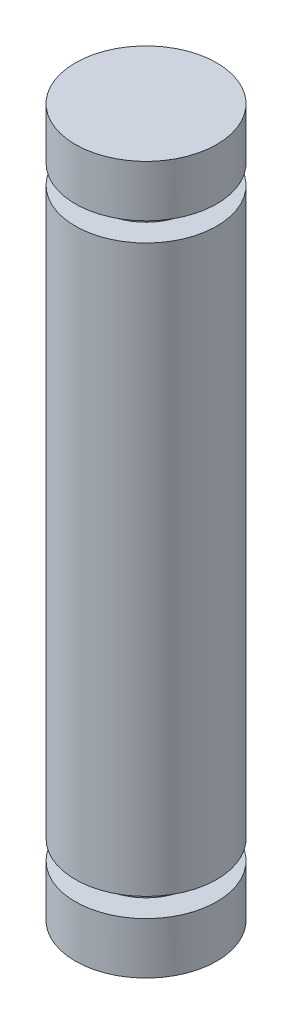
from build123d import *

# Parameters (mm, degrees)
SKETCH2_R           = 2.5
BOSS_EXTRUDE1_DEPTH = 25
SKETCH3_W           = 0.9
SKETCH3_H           = 0.68


with BuildPart() as part:
    # Sketch2 → Boss-Extrude1 (new body)
    with BuildSketch(Plane(origin=(0, 0, 0), x_dir=(1, 0, 0), z_dir=(0, 1, 0))):
        Circle(SKETCH2_R)
    extrude(amount=BOSS_EXTRUDE1_DEPTH)

    # Sketch3 → Cut-Revolve1 (revolve, cut)
    with BuildSketch(Plane(origin=(0, 0, 0), x_dir=(0, 0, -1), z_dir=(1, 0, 0))):
        with Locations((-2.05, 2.16)):
            Rectangle(SKETCH3_W, SKETCH3_H)
        with Locations((-2.05, 22.84)):
            Rectangle(SKETCH3_W, SKETCH3_H)
    revolve(axis=Axis((0, 0, 0), (0, 1, 0)), mode=Mode.SUBTRACT)


solid = part.part
